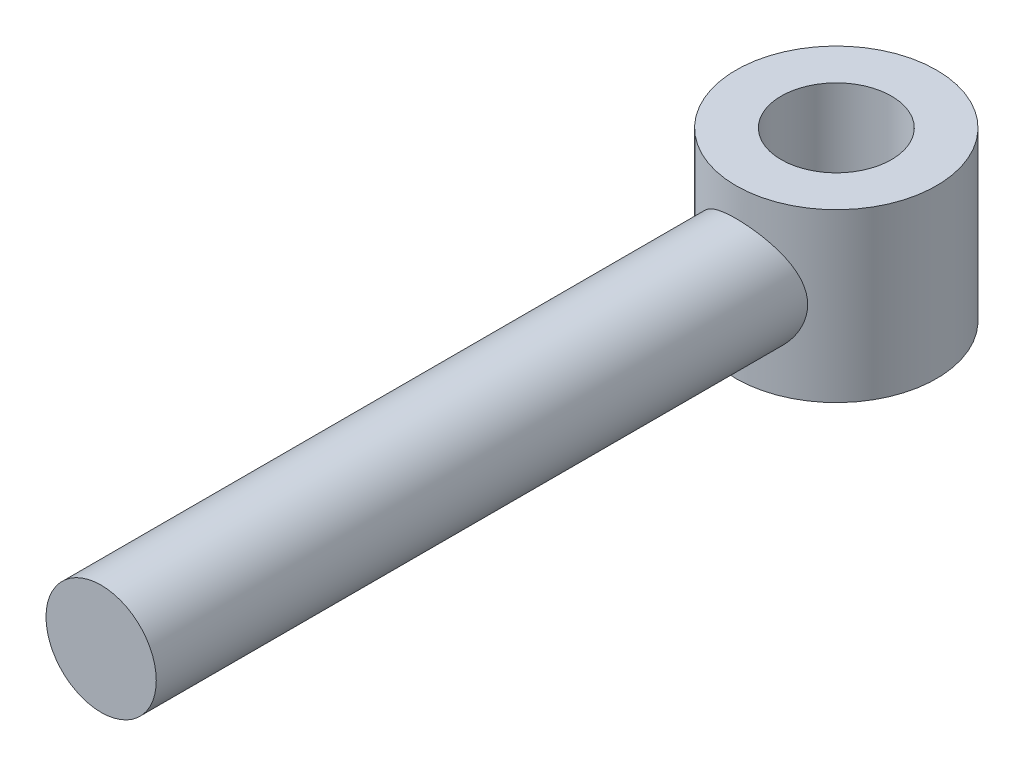
from build123d import *

# Parameters (mm, degrees)
SKICA1_R                 = 1.65
P_IDAT_VYSUNUT_M1_DEPTH  = 20
SKICA2_R                 = 3
P_IDAT_VYSUNUT_M2_DEPTH  = 2.5
SKICA4_R                 = 1.65
ODEBRAT_VYSUNUT_M1_DEPTH = 5


with BuildPart() as part:
    # Skica1 → Přidat vysunutím1 (new body)
    with BuildSketch(Plane.XY):
        Circle(SKICA1_R)
    extrude(amount=P_IDAT_VYSUNUT_M1_DEPTH)

    # Skica2 → Přidat vysunutím2 (add, symmetric)
    with BuildSketch(Plane(origin=(0, 0, 0), x_dir=(1, 0, 0), z_dir=(0, 1, 0))):
        with Locations((0, 2)):
            Circle(SKICA2_R)
    extrude(amount=P_IDAT_VYSUNUT_M2_DEPTH, both=True)

    # Skica4 → Odebrat vysunutím1 (cut)
    with BuildSketch(Plane(origin=(0, 2.5, 0), x_dir=(1, 0, 0), z_dir=(0, 1, 0))):
        with Locations((0, 2.001079416)):
            Circle(SKICA4_R)
    extrude(amount=-ODEBRAT_VYSUNUT_M1_DEPTH, mode=Mode.SUBTRACT)


solid = part.part
